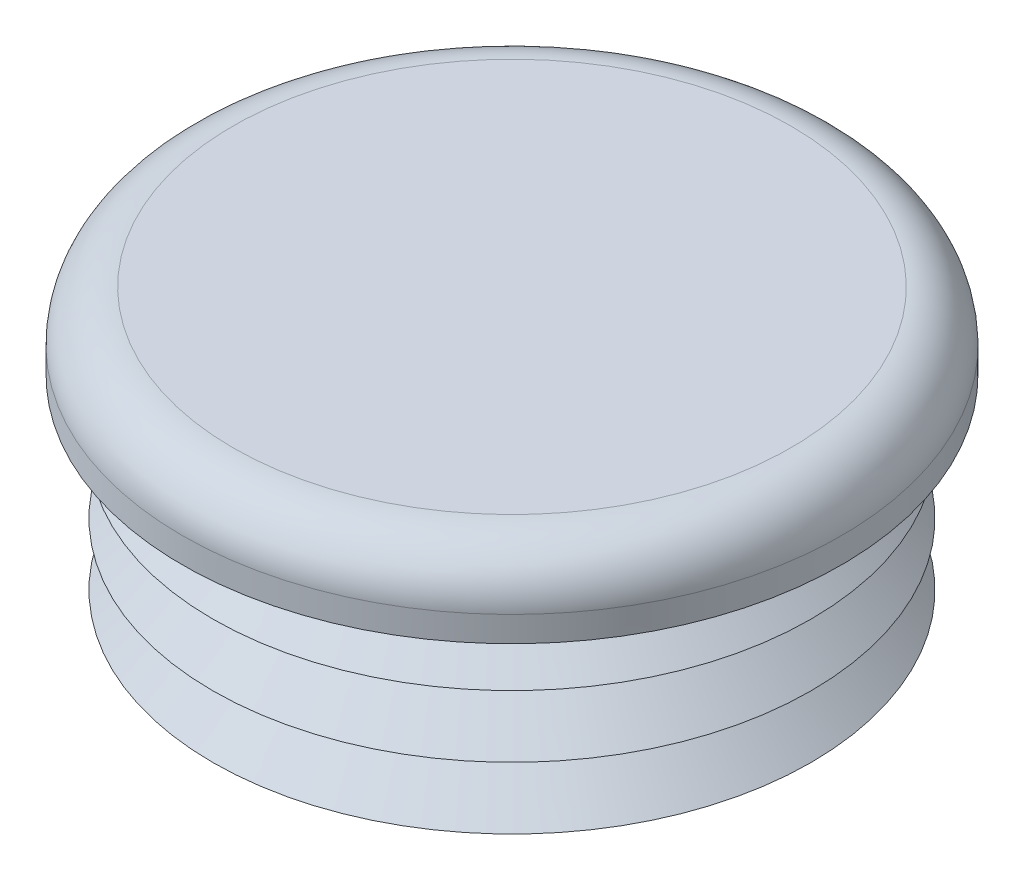
from build123d import *

# Parameters (mm, degrees)
FILLET1_R = 3.175


with BuildPart() as part:
    # Sketch1 → Revolve1 (revolve)
    with BuildSketch(Plane.XY):
        Polygon((15.875, 0), (15.875, 1.031875), (18.7325, 1.031875), (15.875, 3.889375), (15.875, 4.92125), (18.7325, 4.92125), (15.875, 7.77875), (15.875, 8.810625), (18.7325, 8.810625), (15.875, 11.668125), (15.875, 12.7), (20.6375, 12.7), (20.6375, 17.4625), (0, 17.4625), (0, 12.7), (14.9225, 12.7), (14.9225, 0), align=None)
    revolve(axis=Axis((0, 0, 0), (0, 1, 0)))

    # Fillet1
    fillet1_edges = [part.edges().sort_by_distance(p)[0] for p in [
        (-20.6375, 17.4625, 0),
    ]]
    fillet(fillet1_edges, radius=FILLET1_R)


solid = part.part
